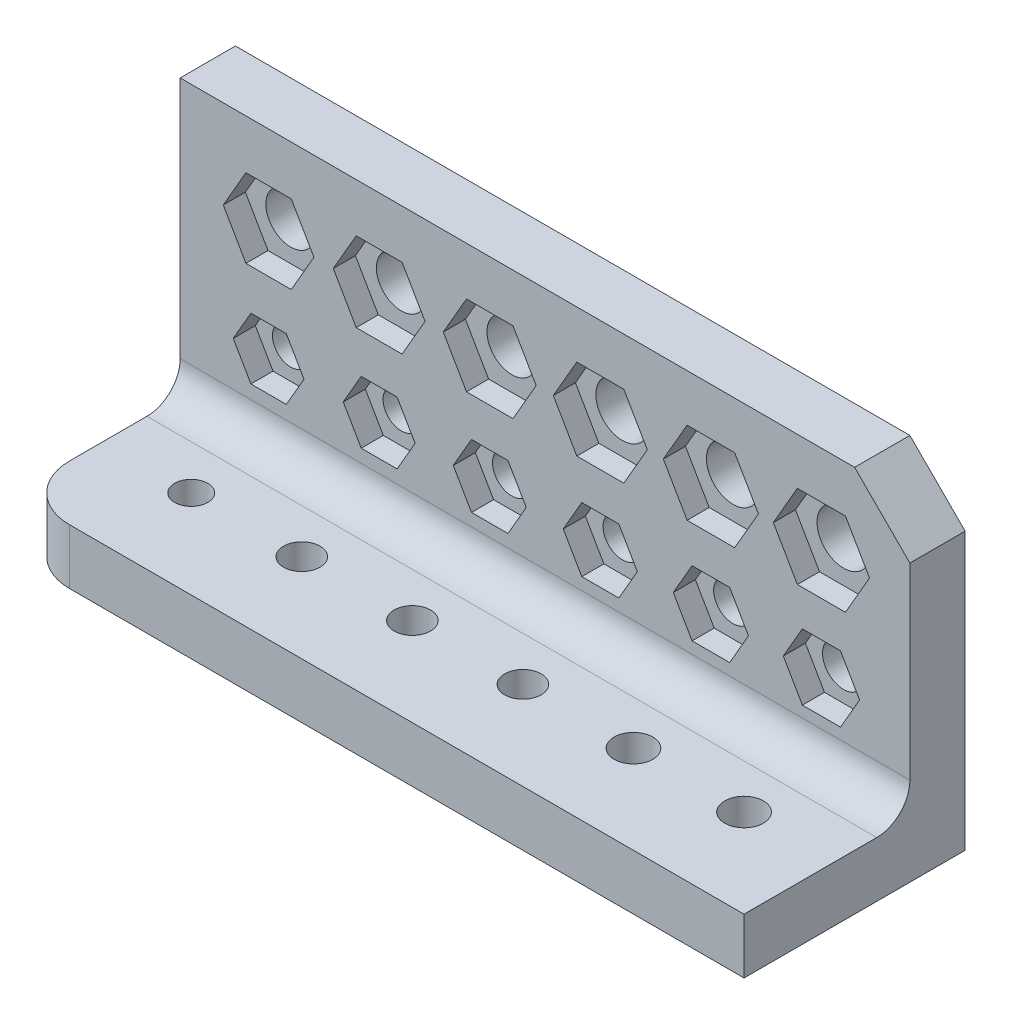
from build123d import *

# Parameters (mm, degrees)
SKETCH_1_W                  = 66
SKETCH_1_H                  = 30
EXTRUDE_1_DEPTH             = 20
SKETCH_2_W                  = 15
SKETCH_2_H                  = 25
CUT_EXTRUDE_1_DEPTH         = 67
CUT_EXTRUDE_2_DEPTH         = 2
CUT_EXTRUDE_3_DEPTH         = 2
CUT_EXTRUDE_4_DEPTH         = 2
CUT_EXTRUDE_5_DEPTH         = 2
CUT_EXTRUDE_6_DEPTH         = 2
CUT_EXTRUDE_7_DEPTH         = 2
CUT_EXTRUDE_8_DEPTH         = 2
CUT_EXTRUDE_9_DEPTH         = 2
CUT_EXTRUDE_10_DEPTH        = 2
CUT_EXTRUDE_11_DEPTH        = 2
CUT_EXTRUDE_12_DEPTH        = 2
CUT_EXTRUDE_13_DEPTH        = 2
CUT_EXTRUDE_14_DEPTH        = 2
CUT_EXTRUDE_15_DEPTH        = 2
CUT_EXTRUDE_16_DEPTH        = 2
CUT_EXTRUDE_17_DEPTH        = 2
CUT_EXTRUDE_18_DEPTH        = 2
CUT_EXTRUDE_19_DEPTH        = 2
HOLE_WIZARD_3_0_3_1_D       = 3
HOLE_WIZARD_3_0_3_1_DEPTH   = 5
HOLE_WIZARD_3_3_3_3_1_D     = 3.3
HOLE_WIZARD_3_3_3_3_1_DEPTH = 5
HOLE_WIZARD_3_5_3_5_1_D     = 3.5
HOLE_WIZARD_3_5_3_5_1_DEPTH = 5
HOLE_WIZARD_3_8_3_8_1_D     = 3.8
HOLE_WIZARD_3_8_3_8_1_DEPTH = 20
HOLE_WIZARD_4_5_4_5_1_D     = 4.5
HOLE_WIZARD_4_5_4_5_1_DEPTH = 20
HOLE_WIZARD_3_5_3_5_2_D     = 3.5
HOLE_WIZARD_3_5_3_5_2_DEPTH = 20
HOLE_WIZARD_4_8_4_8_1_D     = 4.8
HOLE_WIZARD_4_8_4_8_1_DEPTH = 20
HOLE_WIZARD_3_3_3_3_2_D     = 3.3
HOLE_WIZARD_3_3_3_3_2_DEPTH = 20
CHAMFER_1_SIZE              = 5
FILLET_1_R                  = 3
FILLET_2_R                  = 5


with BuildPart() as part:
    # 草图1 → 凸台-拉伸1 (new body)
    with BuildSketch(Plane(origin=(0, 0, 0), x_dir=(-1, 0, 0), z_dir=(0, 0, -1))):
        with Locations((-33, 15)):
            Rectangle(SKETCH_1_W, SKETCH_1_H)
    extrude(amount=-EXTRUDE_1_DEPTH)

    # 草图2 → 切除-拉伸1 (cut, through all)
    with BuildSketch(Plane.ZY):
        with Locations((12.5, 17.5)):
            Rectangle(SKETCH_2_W, SKETCH_2_H)
    extrude(amount=-CUT_EXTRUDE_1_DEPTH, mode=Mode.SUBTRACT)

    # 草图3 → 切除-拉伸2 (cut)
    with BuildSketch(Plane.XZ):
        Polygon((58.142658315, 8.502908551), (61.099899192, 10.375), (60.957240877, 13.872091449), (57.857341685, 15.497091449), (54.900100808, 13.625), (55.042759123, 10.127908551), align=None)
    extrude(amount=-CUT_EXTRUDE_2_DEPTH, mode=Mode.SUBTRACT)

    # 草图4 → 切除-拉伸3 (cut)
    with BuildSketch(Plane.XZ):
        Polygon((48.114375157, 8.551896416), (51.043332877, 10.375), (50.92895772, 13.823103584), (47.885624843, 15.448103584), (44.956667123, 13.625), (45.07104228, 10.176896416), align=None)
    extrude(amount=-CUT_EXTRUDE_3_DEPTH, mode=Mode.SUBTRACT)

    # 草图5 → 切除-拉伸4 (cut)
    with BuildSketch(Plane.XZ):
        Polygon((38.085974854, 8.601087185), (40.98653227, 10.375), (40.900557416, 13.773912815), (37.914025146, 15.398912815), (35.01346773, 13.625), (35.099442584, 10.226087185), align=None)
    extrude(amount=-CUT_EXTRUDE_4_DEPTH, mode=Mode.SUBTRACT)

    # 草图6 → 切除-拉伸5 (cut)
    with BuildSketch(Plane.XZ):
        Polygon((28.05745059, 8.650492659), (30.929483743, 10.375), (30.872033153, 13.724507341), (27.94254941, 15.349507341), (25.070516257, 13.625), (25.127966847, 10.275492659), align=None)
    extrude(amount=-CUT_EXTRUDE_5_DEPTH, mode=Mode.SUBTRACT)

    # 草图7 → 切除-拉伸6 (cut)
    with BuildSketch(Plane.XZ):
        Polygon((18.02879498, 8.700125631), (20.872172523, 10.375), (20.843377542, 13.674874369), (17.97120502, 15.299874369), (15.127827477, 13.625), (15.156622458, 10.325125631), align=None)
    extrude(amount=-CUT_EXTRUDE_6_DEPTH, mode=Mode.SUBTRACT)

    # 草图8 → 切除-拉伸7 (cut)
    with BuildSketch(Plane.XZ):
        Polygon((8, 8.75), (10.814582562, 10.375), (10.814582562, 13.625), (8, 15.25), (5.185417438, 13.625), (5.185417438, 10.375), align=None)
    extrude(amount=-CUT_EXTRUDE_7_DEPTH, mode=Mode.SUBTRACT)

    # 草图9 → 切除-拉伸8 (cut)
    with BuildSketch(Plane.XY.offset(5)):
        Polygon((10.05, 18.449295844), (12.1, 22), (10.05, 25.550704156), (5.95, 25.550704156), (3.9, 22), (5.95, 18.449295844), align=None)
    extrude(amount=-CUT_EXTRUDE_8_DEPTH, mode=Mode.SUBTRACT)

    # 草图10 → 切除-拉伸9 (cut)
    with BuildSketch(Plane.XY.offset(5)):
        Polygon((9.6, 9.228718708), (11.2, 12), (9.6, 14.771281292), (6.4, 14.771281292), (4.8, 12), (6.4, 9.228718708), align=None)
    extrude(amount=-CUT_EXTRUDE_9_DEPTH, mode=Mode.SUBTRACT)

    # 草图11 → 切除-拉伸10 (cut)
    with BuildSketch(Plane.XY.offset(5)):
        Polygon((19.625, 9.185417438), (21.25, 12), (19.625, 14.814582562), (16.375, 14.814582562), (14.75, 12), (16.375, 9.185417438), align=None)
    extrude(amount=-CUT_EXTRUDE_10_DEPTH, mode=Mode.SUBTRACT)

    # 草图12 → 切除-拉伸11 (cut)
    with BuildSketch(Plane.XY.offset(5)):
        Polygon((29.65, 9.142116168), (31.3, 12), (29.65, 14.857883832), (26.35, 14.857883832), (24.7, 12), (26.35, 9.142116168), align=None)
    extrude(amount=-CUT_EXTRUDE_11_DEPTH, mode=Mode.SUBTRACT)

    # 草图13 → 切除-拉伸12 (cut)
    with BuildSketch(Plane.XY.offset(5)):
        Polygon((20.075, 18.405994574), (22.15, 22), (20.075, 25.594005426), (15.925, 25.594005426), (13.85, 22), (15.925, 18.405994574), align=None)
    extrude(amount=-CUT_EXTRUDE_12_DEPTH, mode=Mode.SUBTRACT)

    # 草图14 → 切除-拉伸13 (cut)
    with BuildSketch(Plane.XY.offset(5)):
        Polygon((30.1, 18.362693304), (32.2, 22), (30.1, 25.637306696), (25.9, 25.637306696), (23.8, 22), (25.9, 18.362693304), align=None)
    extrude(amount=-CUT_EXTRUDE_13_DEPTH, mode=Mode.SUBTRACT)

    # 草图15 → 切除-拉伸14 (cut)
    with BuildSketch(Plane.XY.offset(5)):
        Polygon((40.125, 18.319392034), (42.25, 22), (40.125, 25.680607966), (35.875, 25.680607966), (33.75, 22), (35.875, 18.319392034), align=None)
    extrude(amount=-CUT_EXTRUDE_14_DEPTH, mode=Mode.SUBTRACT)

    # 草图16 → 切除-拉伸15 (cut)
    with BuildSketch(Plane.XY.offset(5)):
        Polygon((50.15, 18.276090764), (52.3, 22), (50.15, 25.723909236), (45.85, 25.723909236), (43.7, 22), (45.85, 18.276090764), align=None)
    extrude(amount=-CUT_EXTRUDE_15_DEPTH, mode=Mode.SUBTRACT)

    # 草图17 → 切除-拉伸16 (cut)
    with BuildSketch(Plane.XY.offset(5)):
        Polygon((60.175, 18.232789494), (62.35, 22), (60.175, 25.767210506), (55.825, 25.767210506), (53.65, 22), (55.825, 18.232789494), align=None)
    extrude(amount=-CUT_EXTRUDE_16_DEPTH, mode=Mode.SUBTRACT)

    # 草图18 → 切除-拉伸17 (cut)
    with BuildSketch(Plane.XY.offset(5)):
        Polygon((59.725, 9.012212357), (61.45, 12), (59.725, 14.987787643), (56.275, 14.987787643), (54.55, 12), (56.275, 9.012212357), align=None)
    extrude(amount=-CUT_EXTRUDE_17_DEPTH, mode=Mode.SUBTRACT)

    # 草图19 → 切除-拉伸18 (cut)
    with BuildSketch(Plane.XY.offset(5)):
        Polygon((49.7, 9.055513627), (51.4, 12), (49.7, 14.944486373), (46.3, 14.944486373), (44.6, 12), (46.3, 9.055513627), align=None)
    extrude(amount=-CUT_EXTRUDE_18_DEPTH, mode=Mode.SUBTRACT)

    # 草图20 → 切除-拉伸19 (cut)
    with BuildSketch(Plane.XY.offset(5)):
        Polygon((39.675, 9.098814897), (41.35, 12), (39.675, 14.901185103), (36.325, 14.901185103), (34.65, 12), (36.325, 9.098814897), align=None)
    extrude(amount=-CUT_EXTRUDE_19_DEPTH, mode=Mode.SUBTRACT)

    # Ø3.0 (3) 直径孔1
    with Locations(Plane(origin=(0, 5, 0), x_dir=(1, 0, 0), z_dir=(0, 1, 0))):
        with Locations((8, -12)):
            Hole(HOLE_WIZARD_3_0_3_1_D / 2, depth=HOLE_WIZARD_3_0_3_1_DEPTH)

    # Ø3.3 (3.3) 直径孔1
    with Locations(Plane(origin=(0, 5, 0), x_dir=(1, 0, 0), z_dir=(0, 1, 0))):
        with Locations((38, -12), (28, -12), (18, -12)):
            Hole(HOLE_WIZARD_3_3_3_3_1_D / 2, depth=HOLE_WIZARD_3_3_3_3_1_DEPTH)

    # Ø3.5 (3.5) 直径孔1
    with Locations(Plane(origin=(0, 5, 0), x_dir=(1, 0, 0), z_dir=(0, 1, 0))):
        with Locations((58, -12), (48, -12)):
            Hole(HOLE_WIZARD_3_5_3_5_1_D / 2, depth=HOLE_WIZARD_3_5_3_5_1_DEPTH)

    # Ø3.8 (3.8) 直径孔1
    with Locations(Plane(origin=(0, 0, 0), x_dir=(-1, 0, 0), z_dir=(0, 0, -1))):
        with Locations((-58, 12)):
            Hole(HOLE_WIZARD_3_8_3_8_1_D / 2, depth=HOLE_WIZARD_3_8_3_8_1_DEPTH)

    # Ø4.5 (4.5) 直径孔1
    with Locations(Plane(origin=(0, 0, 0), x_dir=(-1, 0, 0), z_dir=(0, 0, -1))):
        with Locations((-28, 22), (-18, 22), (-8, 22)):
            Hole(HOLE_WIZARD_4_5_4_5_1_D / 2, depth=HOLE_WIZARD_4_5_4_5_1_DEPTH)

    # Ø3.5 (3.5) 直径孔2
    with Locations(Plane(origin=(0, 0, 0), x_dir=(-1, 0, 0), z_dir=(0, 0, -1))):
        with Locations((-28, 12), (-38, 12), (-48, 12)):
            Hole(HOLE_WIZARD_3_5_3_5_2_D / 2, depth=HOLE_WIZARD_3_5_3_5_2_DEPTH)

    # Ø4.8 (4.8) 直径孔1
    with Locations(Plane(origin=(0, 0, 0), x_dir=(-1, 0, 0), z_dir=(0, 0, -1))):
        with Locations((-58, 22), (-48, 22), (-38, 22)):
            Hole(HOLE_WIZARD_4_8_4_8_1_D / 2, depth=HOLE_WIZARD_4_8_4_8_1_DEPTH)

    # Ø3.3 (3.3) 直径孔2
    with Locations(Plane(origin=(0, 0, 0), x_dir=(-1, 0, 0), z_dir=(0, 0, -1))):
        with Locations((-8, 12), (-18, 12)):
            Hole(HOLE_WIZARD_3_3_3_3_2_D / 2, depth=HOLE_WIZARD_3_3_3_3_2_DEPTH)

    # 倒角1
    chamfer_1_edges = [part.edges().sort_by_distance(p)[0] for p in [
        (66, 30, 2.5),
    ]]
    chamfer(chamfer_1_edges, length=CHAMFER_1_SIZE)

    # 圆角1
    fillet_1_edges = [part.edges().sort_by_distance(p)[0] for p in [
        (33, 5, 5),
    ]]
    fillet(fillet_1_edges, radius=FILLET_1_R)

    # 圆角2
    fillet_2_edges = [part.edges().sort_by_distance(p)[0] for p in [
        (0, 2.5, 20),
    ]]
    fillet(fillet_2_edges, radius=FILLET_2_R)


solid = part.part
